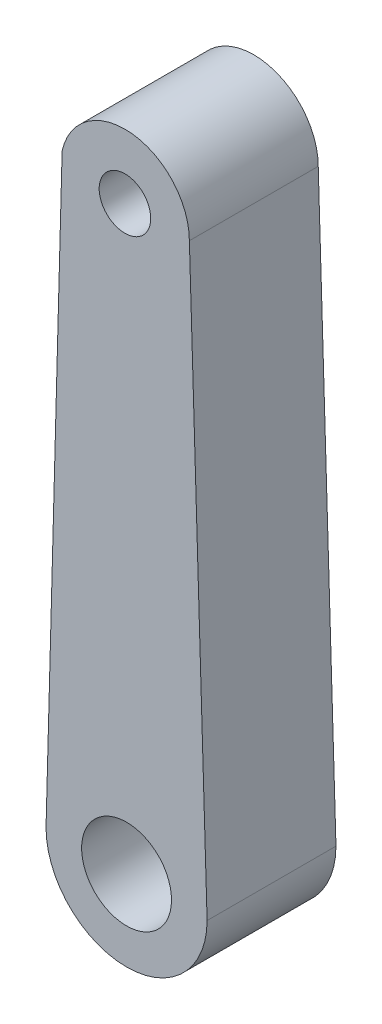
from build123d import *

# Parameters (mm, degrees)
EXTRUDE1_DEPTH     = 10
SKETCH6_R          = 4
CUT_EXTRUDE1_DEPTH = 21
SKETCH8_R          = 6.975
CUT_EXTRUDE2_DEPTH = 21


with BuildPart() as part:
    # Sketch2 → Extrude1 (new body, symmetric)
    with BuildSketch(Plane.XY):
        with BuildLine():
            Line((-12.5, 0), (-10, 92.232909937))
            ThreePointArc((-10, 92.232909937), (0.871187265, 99.936304296), (9.747437125, 89.999645621))
            Line((9.747437125, 89.999645621), (12.5, 0))
            ThreePointArc((12.5, 0), (0, -12.5), (-12.5, 0))
        make_face()
    extrude(amount=EXTRUDE1_DEPTH, both=True)

    # Sketch6 → Cut-Extrude1 (cut, through all)
    with BuildSketch(Plane.XY.offset(10)):
        with Locations((-0.252562875, 89.999645621)):
            Circle(SKETCH6_R)
    extrude(amount=-CUT_EXTRUDE1_DEPTH, mode=Mode.SUBTRACT)

    # Sketch8 → Cut-Extrude2 (cut, through all)
    with BuildSketch(Plane.XY.offset(10)):
        Circle(SKETCH8_R)
    extrude(amount=-CUT_EXTRUDE2_DEPTH, mode=Mode.SUBTRACT)


solid = part.part
